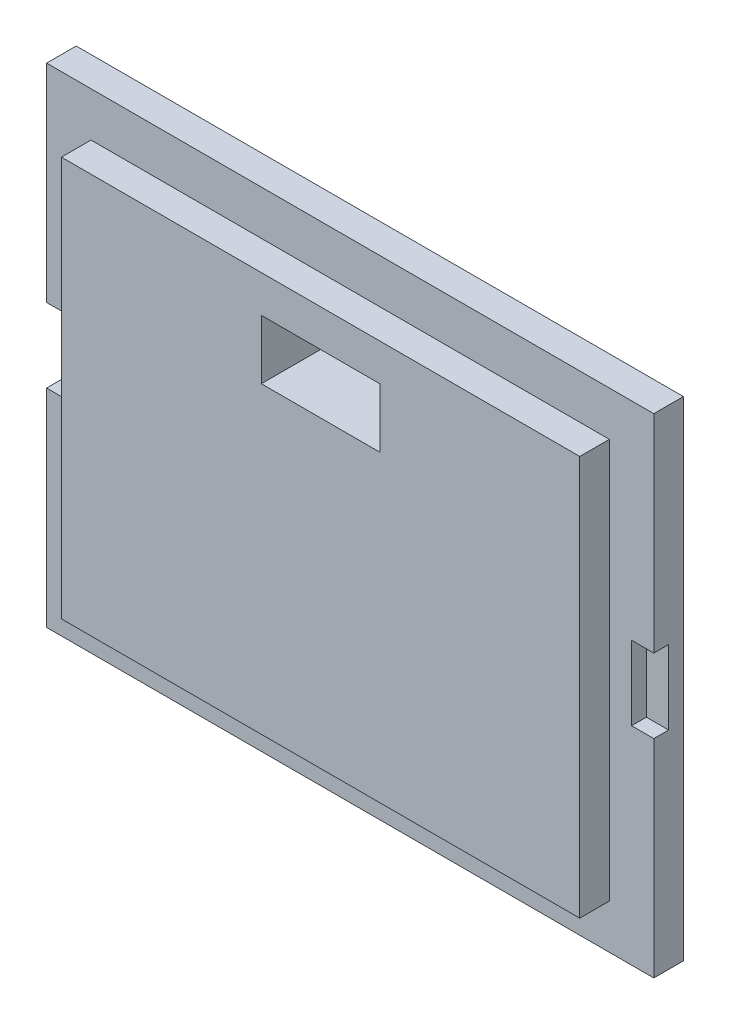
from build123d import *

# Parameters (mm, degrees)
SKETCH_1_W          = 41
SKETCH_1_H          = 33
EXTRUDE_1_DEPTH     = 2
SKETCH_2_W          = 35
SKETCH_2_H          = 27
EXTRUDE_2_DEPTH     = 2
SKETCH_3_W          = 8
SKETCH_3_H          = 4
CUT_EXTRUDE_1_DEPTH = 5
SKETCH_5_W          = 1.5
SKETCH_5_H          = 5
CUT_EXTRUDE_2_DEPTH = 1


with BuildPart() as part:
    # Эскиз1 → Бобышка-Вытянуть1 (new body)
    with BuildSketch(Plane.XY):
        Rectangle(SKETCH_1_W, SKETCH_1_H)
    extrude(amount=EXTRUDE_1_DEPTH)

    # Эскиз2 → Бобышка-Вытянуть2 (add)
    with BuildSketch(Plane.XY.offset(2)):
        Rectangle(SKETCH_2_W, SKETCH_2_H)
    extrude(amount=EXTRUDE_2_DEPTH)

    # Эскиз3 → Вырез-Вытянуть1 (cut)
    with BuildSketch(Plane.XY.offset(4)):
        with Locations((0, 9)):
            Rectangle(SKETCH_3_W, SKETCH_3_H)
    extrude(amount=-CUT_EXTRUDE_1_DEPTH, mode=Mode.SUBTRACT)

    # Эскиз5 → Вырез-Вытянуть2 (cut)
    with BuildSketch(Plane.XY.offset(2)):
        with Locations((-19.75, 0)):
            Rectangle(SKETCH_5_W, SKETCH_5_H)
        with Locations((19.75, 0)):
            Rectangle(SKETCH_5_W, SKETCH_5_H)
    extrude(amount=-CUT_EXTRUDE_2_DEPTH, mode=Mode.SUBTRACT)


solid = part.part
